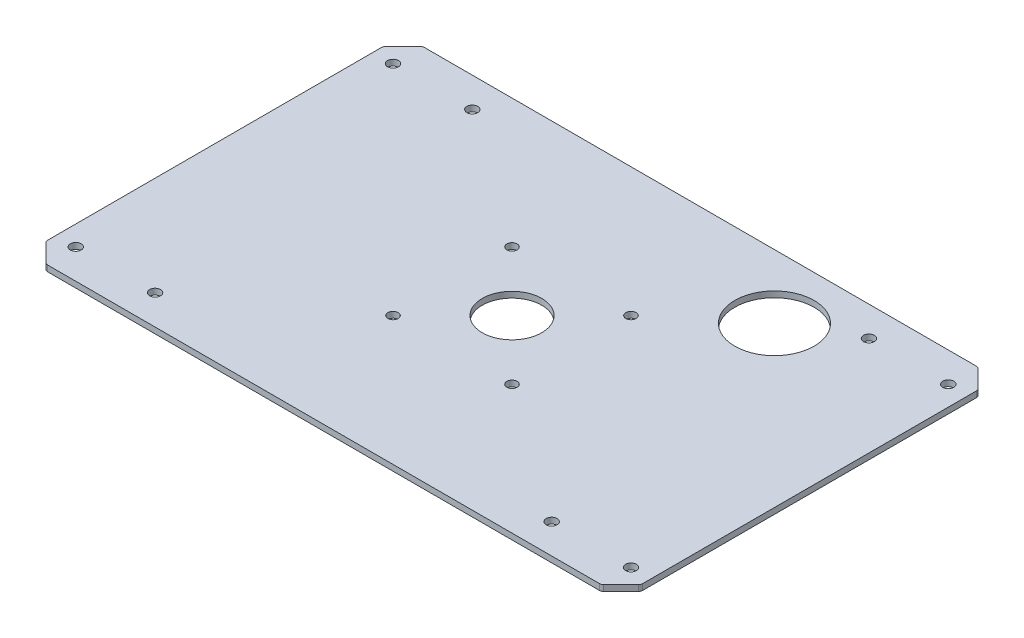
from build123d import *

# Parameters (mm, degrees)
ESQUISSE1_W                     = 300
ESQUISSE1_H                     = 190
BOSS_EXTRU_1_DEPTH              = 3
CHANFREIN1_SIZE                 = 10
CONG_1_R                        = 2
ESQUISSE2_R                     = 2.75
ENL_V_MAT_EXTRU_1_DEPTH         = 4
R_P_TITION_LIN_AIRE1_COUNT      = 2
R_P_TITION_LIN_AIRE1_PITCH      = 240
R_P_TITION_LIN_AIRE1_COUNT_DIR2 = 2
R_P_TITION_LIN_AIRE1_PITCH_DIR2 = 160
ESQUISSE4_R                     = 2.75
ESQUISSE4_R_2                   = 20
ESQUISSE4_R_3                   = 15
ENL_V_MAT_EXTRU_3_DEPTH         = 10
ESQUISSE5_R                     = 2.6
ENL_V_MAT_EXTRU_4_DEPTH         = 4


with BuildPart() as part:
    # Esquisse1 → Boss.-Extru.1 (new body)
    with BuildSketch(Plane(origin=(0, 0, 0), x_dir=(1, 0, 0), z_dir=(0, 1, 0))):
        Rectangle(ESQUISSE1_W, ESQUISSE1_H)
    extrude(amount=BOSS_EXTRU_1_DEPTH)

    # Chanfrein1
    chanfrein1_edges = [part.edges().sort_by_distance(p)[0] for p in [
        (150, 1.5, 95),
        (-150, 1.5, 95),
        (-150, 1.5, -95),
        (150, 1.5, -95),
    ]]
    chamfer(chanfrein1_edges, length=CHANFREIN1_SIZE)

    # Congé1
    cong_1_edges = [part.edges().sort_by_distance(p)[0] for p in [
        (140, 1.5, 95),
        (-140, 1.5, 95),
        (-150, 1.5, -85),
        (-150, 1.5, 85),
        (150, 1.5, -85),
        (150, 1.5, 85),
        (-140, 1.5, -95),
        (140, 1.5, -95),
    ]]
    fillet(cong_1_edges, radius=CONG_1_R)

    # Esquisse2 → Enlèv. mat.-Extru.1 (cut, through all)
    with BuildSketch(Plane.XZ):
        with Locations((-140, 80)):
            Circle(ESQUISSE2_R)
        with Locations((-100, 80)):
            Circle(ESQUISSE2_R)
    enl_v_mat_extru_1 = extrude(amount=-ENL_V_MAT_EXTRU_1_DEPTH, mode=Mode.SUBTRACT)

    # Répétition linéaire1: Enl_v. mat.-Extru.1 2 × 2
    with Locations(*[(i * R_P_TITION_LIN_AIRE1_PITCH, 0, -j * R_P_TITION_LIN_AIRE1_PITCH_DIR2) for i in range(R_P_TITION_LIN_AIRE1_COUNT) for j in range(R_P_TITION_LIN_AIRE1_COUNT_DIR2) if (i, j) != (0, 0)]):
        add(enl_v_mat_extru_1, mode=Mode.SUBTRACT)

    # Esquisse4 → Enlèv. mat.-Extru.3 (cut)
    with BuildSketch(Plane(origin=(0, 3, 0), x_dir=(1, 0, 0), z_dir=(0, 1, 0))):
        with Locations((100, 80)):
            Circle(ESQUISSE4_R)
        with Locations((69.55, 62.8)):
            Circle(ESQUISSE4_R_2)
        Circle(ESQUISSE4_R_3)
    extrude(amount=-ENL_V_MAT_EXTRU_3_DEPTH, mode=Mode.SUBTRACT)

    # Esquisse5 → Enlèv. mat.-Extru.4 (cut, through all)
    with BuildSketch(Plane(origin=(0, 3, 0), x_dir=(1, 0, 0), z_dir=(0, 1, 0))):
        with Locations((-30, 30)):
            Circle(ESQUISSE5_R)
        with Locations((30, 30)):
            Circle(ESQUISSE5_R)
        with Locations((30, -30)):
            Circle(ESQUISSE5_R)
        with Locations((-30, -30)):
            Circle(ESQUISSE5_R)
    extrude(amount=-ENL_V_MAT_EXTRU_4_DEPTH, mode=Mode.SUBTRACT)


solid = part.part
